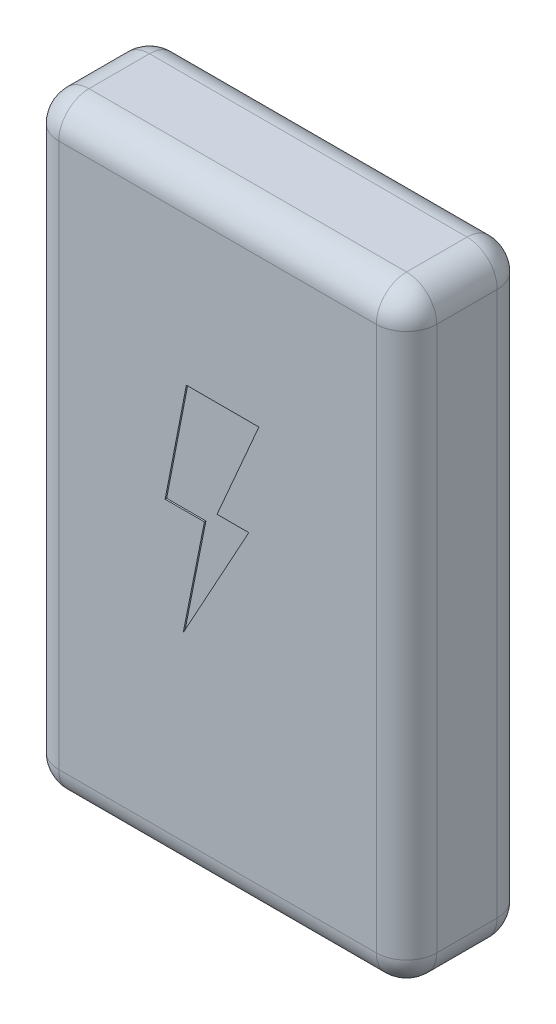
from build123d import *

# Parameters (mm, degrees)
SKETCH1_W           = 25
SKETCH1_H           = 40
BOSS_EXTRUDE1_DEPTH = 8
FILLET1_R           = 2
CUT_EXTRUDE1_DEPTH  = 0.1


with BuildPart() as part:
    # Sketch1 → Boss-Extrude1 (new body)
    with BuildSketch(Plane.XY):
        Rectangle(SKETCH1_W, SKETCH1_H)
    extrude(amount=BOSS_EXTRUDE1_DEPTH)

    # Fillet1
    fillet1_edges = [part.edges().sort_by_distance(p)[0] for p in [
        (-12.5, 0, 8),
        (0, -20, 8),
        (12.5, 0, 8),
        (0, -20, 0),
        (-12.5, 0, 0),
        (0, 20, 0),
        (12.5, 0, 0),
        (12.5, -20, 4),
        (-12.5, -20, 4),
        (-12.5, 20, 4),
        (12.5, 20, 4),
        (0, 20, 8),
    ]]
    fillet(fillet1_edges, radius=FILLET1_R)

    # Sketch2 → Cut-Extrude1 (cut)
    with BuildSketch(Plane.XY.offset(8)):
        Polygon((-2.061020471, 8.237438207), (2.736573232, 8.237438207), (-0.031843364, 1.854183508), (2.068180648, 1.854183508), (-2.268382383, -6.039716385), (-0.867604628, 1.003082881), (-3.464302761, 1.003082881), align=None)
    extrude(amount=-CUT_EXTRUDE1_DEPTH, mode=Mode.SUBTRACT)


solid = part.part
